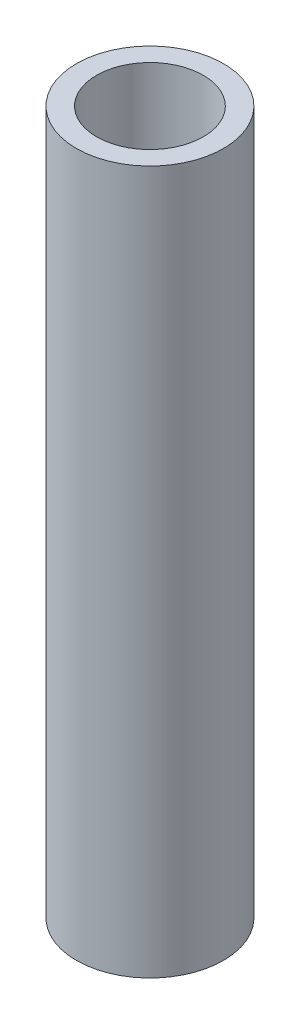
from build123d import *

# Parameters (mm, degrees)
SKETCH1_R           = 10.615
SKETCH1_R_2         = 7.7
BOSS_EXTRUDE1_DEPTH = 101.5
SKETCH2_R           = 7.7
SKETCH2_R_2         = 3
BOSS_EXTRUDE2_DEPTH = 12.91


with BuildPart() as part:
    # Sketch1 → Boss-Extrude1 (new body)
    with BuildSketch(Plane(origin=(0, 0, 0), x_dir=(1, 0, 0), z_dir=(0, 1, 0))):
        Circle(SKETCH1_R)
        Circle(SKETCH1_R_2, mode=Mode.SUBTRACT)
    extrude(amount=BOSS_EXTRUDE1_DEPTH)

    # Sketch2 → Boss-Extrude2 (add)
    with BuildSketch(Plane(origin=(0, 0, 0), x_dir=(1, 0, 0), z_dir=(0, 1, 0))):
        Circle(SKETCH2_R)
        Circle(SKETCH2_R_2, mode=Mode.SUBTRACT)
    extrude(amount=BOSS_EXTRUDE2_DEPTH)


solid = part.part
